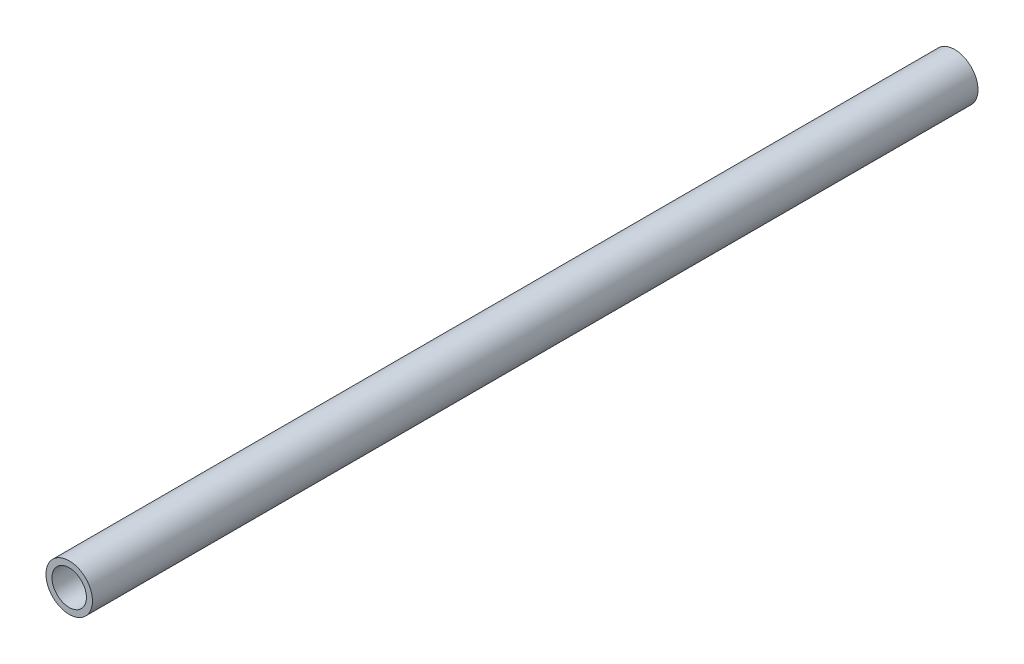
from build123d import *

# Parameters (mm, degrees)
SKETCH1_R           = 10.668
SKETCH1_R_2         = 7.8994
EXTRUDE_THIN1_DEPTH = 203.25


with BuildPart() as part:
    # Sketch1 → Extrude-Thin1 (new body, symmetric)
    with BuildSketch(Plane.XY):
        Circle(SKETCH1_R)
        Circle(SKETCH1_R_2, mode=Mode.SUBTRACT)
    extrude(amount=EXTRUDE_THIN1_DEPTH, both=True)


solid = part.part
